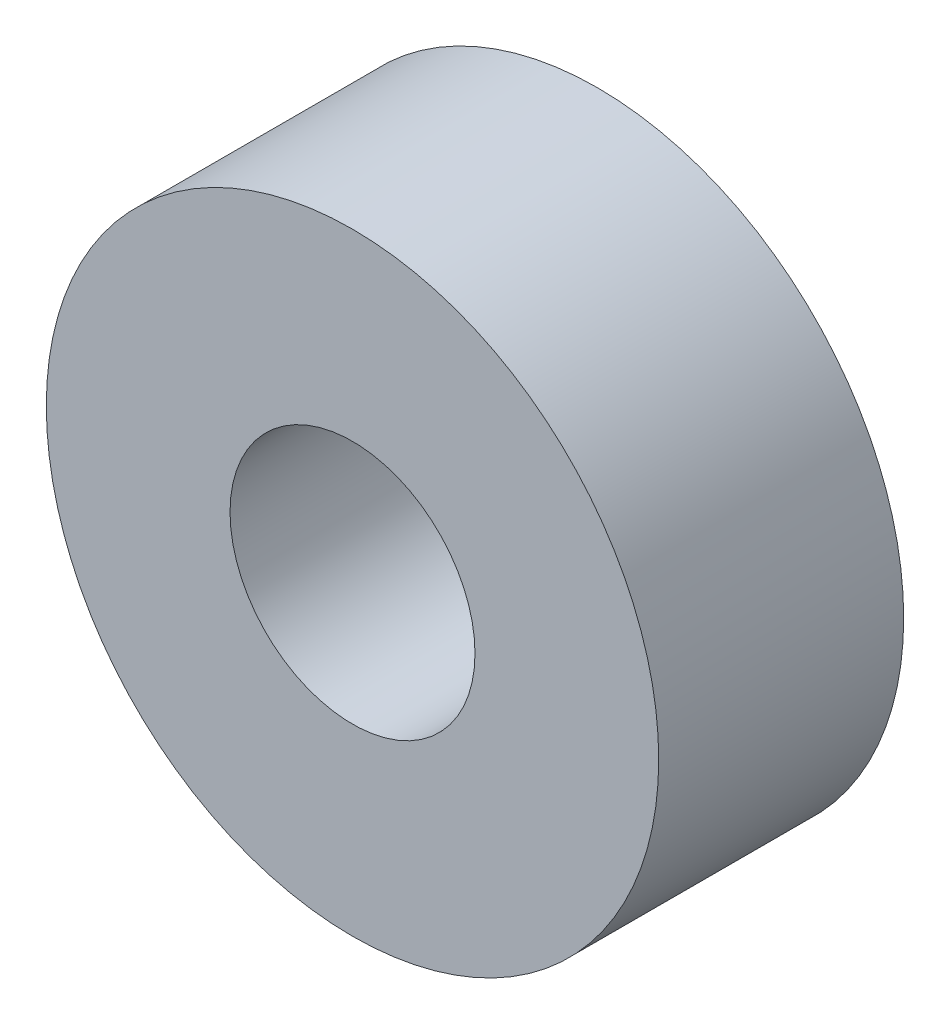
from build123d import *

# Parameters (mm, degrees)
SKETCH_1_R          = 5
EXTRUDE_1_DEPTH     = 4
SKETCH_2_R          = 2
CUT_EXTRUDE_1_DEPTH = 5


with BuildPart() as part:
    # 草图1 → 凸台-拉伸1 (new body)
    with BuildSketch(Plane.XY):
        with Locations((-11.837070281, 28.24755408)):
            Circle(SKETCH_1_R)
    extrude(amount=EXTRUDE_1_DEPTH)

    # 草图2 → 切除-拉伸1 (cut, through all)
    with BuildSketch(Plane.XY.offset(4)):
        with Locations((-11.837070281, 28.24755408)):
            Circle(SKETCH_2_R)
    extrude(amount=-CUT_EXTRUDE_1_DEPTH, mode=Mode.SUBTRACT)


solid = part.part
